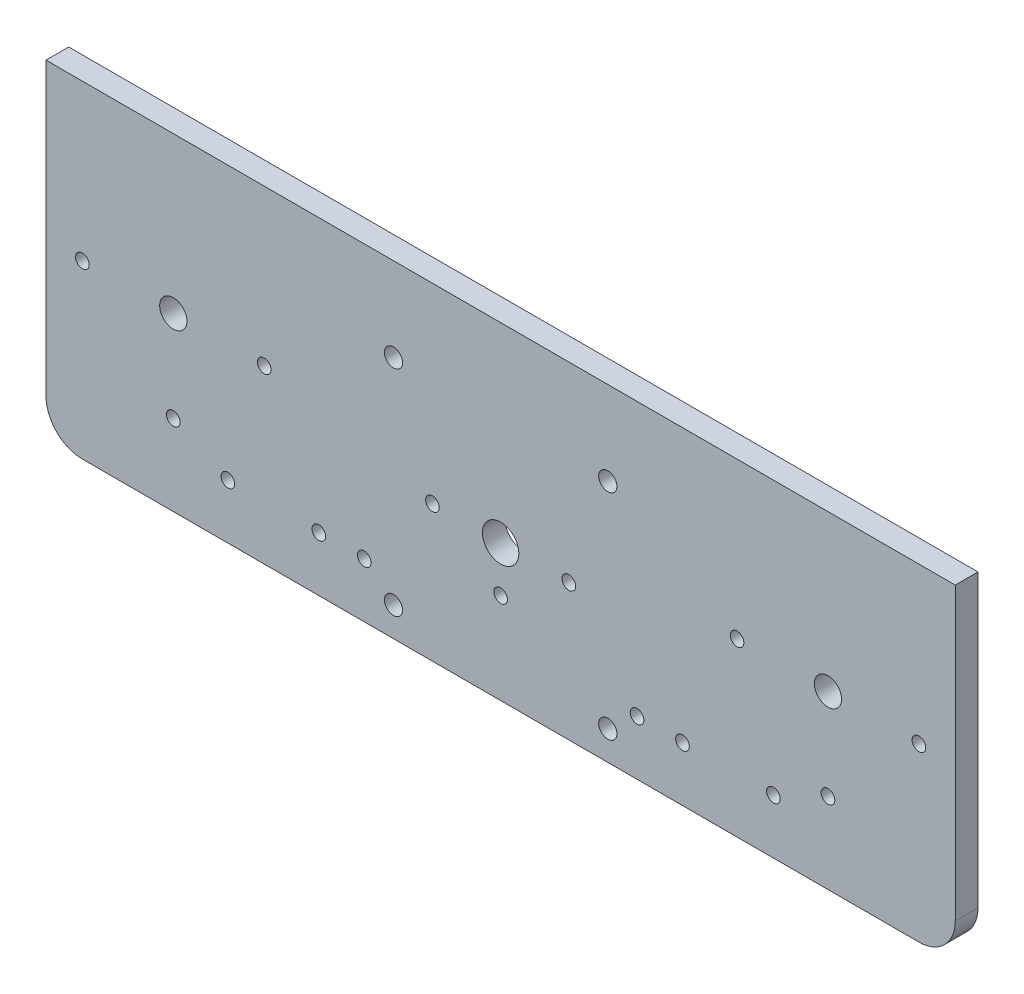
from build123d import *

# Parameters (mm, degrees)
CROQUIS1_R              = 4
CROQUIS1_R_2            = 3
CROQUIS1_R_3            = 1.5
CROQUIS1_R_4            = 2
SALIENTE_EXTRUIR1_DEPTH = 5


with BuildPart() as part:
    # Croquis1 → Saliente-Extruir1 (new body)
    with BuildSketch(Plane.XY):
        with BuildLine():
            Line((102.068487159, -0.327277931), (102.068487159, -49.327277931))
            ThreePointArc((102.068487159, -49.327277931), (99.725341409, -54.98413218), (94.068487159, -57.327277931))
            Line((94.068487159, -57.327277931), (-89.931512841, -57.327277931))
            ThreePointArc((-89.931512841, -57.327277931), (-95.58836709, -54.98413218), (-97.931512841, -49.327277931))
            Line((-97.931512841, -49.327277931), (-97.931512841, -0.327277931))
            Line((-97.931512841, -0.327277931), (-97.931512841, 14.672722069))
            Line((-97.931512841, 14.672722069), (102.068487159, 14.672722069))
            Line((102.068487159, 14.672722069), (102.068487159, -0.327277931))
        make_face()
        with Locations((2.068487159, -27.327277931)):
            Circle(CROQUIS1_R, mode=Mode.SUBTRACT)
        with Locations((74.068487159, -19.577277931)):
            Circle(CROQUIS1_R_2, mode=Mode.SUBTRACT)
        with Locations((-69.931512841, -19.577277931)):
            Circle(CROQUIS1_R_2, mode=Mode.SUBTRACT)
        with Locations((74.068487159, -39.577277931)):
            Circle(CROQUIS1_R_3, mode=Mode.SUBTRACT)
        with Locations((54.068487159, -19.577277931)):
            Circle(CROQUIS1_R_3, mode=Mode.SUBTRACT)
        with Locations((94.068487159, -19.577277931)):
            Circle(CROQUIS1_R_3, mode=Mode.SUBTRACT)
        with Locations((-69.931512841, -39.577277931)):
            Circle(CROQUIS1_R_3, mode=Mode.SUBTRACT)
        with Locations((-89.931512841, -19.577277931)):
            Circle(CROQUIS1_R_3, mode=Mode.SUBTRACT)
        with Locations((-49.931512841, -19.577277931)):
            Circle(CROQUIS1_R_3, mode=Mode.SUBTRACT)
        with Locations((42.068487159, -45.327277931)):
            Circle(CROQUIS1_R_3, mode=Mode.SUBTRACT)
        with Locations((62.068487159, -45.327277931)):
            Circle(CROQUIS1_R_3, mode=Mode.SUBTRACT)
        with Locations((-57.931512841, -45.327277931)):
            Circle(CROQUIS1_R_3, mode=Mode.SUBTRACT)
        with Locations((-37.931512841, -45.327277931)):
            Circle(CROQUIS1_R_3, mode=Mode.SUBTRACT)
        with Locations((-12.931512841, -27.327277931)):
            Circle(CROQUIS1_R_3, mode=Mode.SUBTRACT)
        with Locations((17.068487159, -27.327277931)):
            Circle(CROQUIS1_R_3, mode=Mode.SUBTRACT)
        with Locations((2.068487159, -37.327277931)):
            Circle(CROQUIS1_R_3, mode=Mode.SUBTRACT)
        with Locations((-21.501512841, -3.757277931)):
            Circle(CROQUIS1_R_4, mode=Mode.SUBTRACT)
        with Locations((25.638487159, -3.757277931)):
            Circle(CROQUIS1_R_4, mode=Mode.SUBTRACT)
        with Locations((25.638487159, -50.897277931)):
            Circle(CROQUIS1_R_4, mode=Mode.SUBTRACT)
        with Locations((-21.501512841, -50.897277931)):
            Circle(CROQUIS1_R_4, mode=Mode.SUBTRACT)
        with Locations((32.068487159, -45.327277931)):
            Circle(CROQUIS1_R_3, mode=Mode.SUBTRACT)
        with Locations((-27.931512841, -45.327277931)):
            Circle(CROQUIS1_R_3, mode=Mode.SUBTRACT)
    extrude(amount=SALIENTE_EXTRUIR1_DEPTH)


solid = part.part
